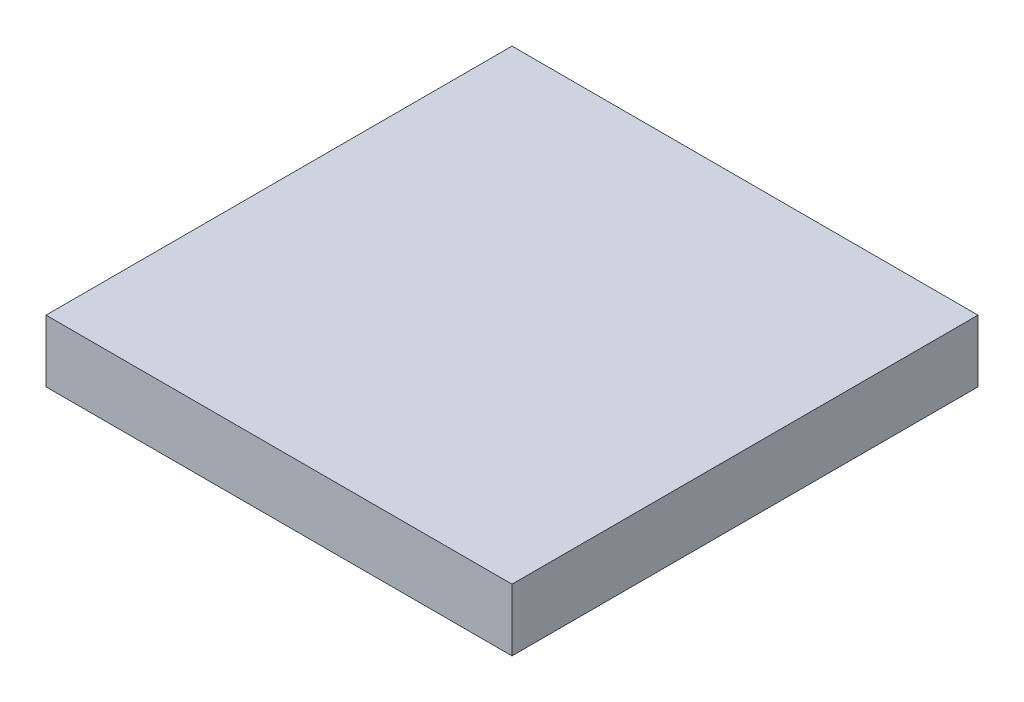
from build123d import *

# Parameters (mm, degrees)
SKETCH1_W           = 12
SKETCH1_H           = 12
BOSS_EXTRUDE1_DEPTH = 1.6


with BuildPart() as part:
    # Sketch1 → Boss-Extrude1 (new body)
    with BuildSketch(Plane(origin=(0, 0, 0), x_dir=(1, 0, 0), z_dir=(0, 1, 0))):
        with Locations((6, 6)):
            Rectangle(SKETCH1_W, SKETCH1_H)
    extrude(amount=BOSS_EXTRUDE1_DEPTH)


solid = part.part
